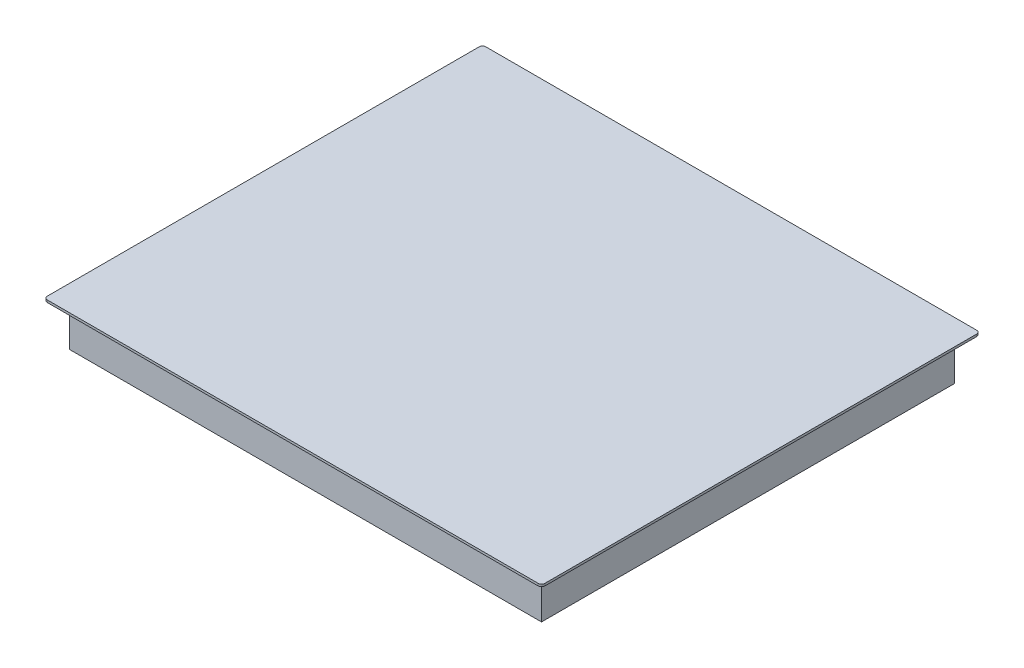
from build123d import *

# Parameters (mm, degrees)
SKETCH1_W           = 590
SKETCH1_H           = 520
BOSS_EXTRUDE1_DEPTH = 2.7
SKETCH2_W           = 560
SKETCH2_H           = 490
BOSS_EXTRUDE2_DEPTH = 50
FILLET1_R           = 4


with BuildPart() as part:
    # Sketch1 → Boss-Extrude1 (new body)
    with BuildSketch(Plane(origin=(0, 0, 0), x_dir=(1, 0, 0), z_dir=(0, 1, 0))):
        Rectangle(SKETCH1_W, SKETCH1_H)
    extrude(amount=BOSS_EXTRUDE1_DEPTH)

    # Sketch2 → Boss-Extrude2 (add)
    with BuildSketch(Plane.XZ):
        Rectangle(SKETCH2_W, SKETCH2_H)
    extrude(amount=BOSS_EXTRUDE2_DEPTH)

    # Fillet1
    fillet1_edges = [part.edges().sort_by_distance(p)[0] for p in [
        (-295, 1.35, -260),
        (295, 1.35, -260),
        (295, 1.35, 260),
        (-295, 1.35, 260),
    ]]
    fillet(fillet1_edges, radius=FILLET1_R)


solid = part.part
